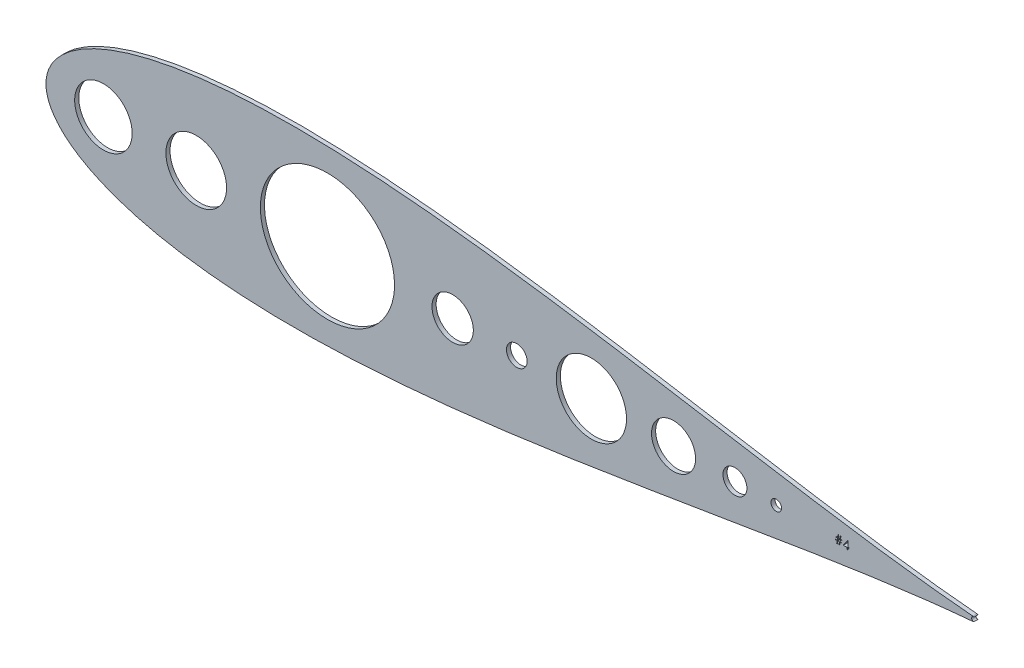
from build123d import *

# Parameters (mm, degrees)
SKETCH2_R           = 17.657288519
SKETCH2_R_2         = 3.25497866
SKETCH2_R_3         = 7.363621317
SKETCH2_R_4         = 13.535095818
SKETCH2_R_5         = 21.574235763
SKETCH2_R_6         = 6.35
SKETCH2_R_7         = 12.7
SKETCH2_R_8         = 18.6309
SKETCH2_RX          = 41.194524799
SKETCH2_RY          = 38.943193852
BOSS_EXTRUDE1_DEPTH = 2.54


with BuildPart() as part:
    # Sketch2 → Boss-Extrude1 (new body)
    with BuildSketch(Plane.XY):
        with BuildLine():
            ThreePointArc((862.057835852, 526.923410091), (860.658736729, 525.688436739), (862.057835852, 524.453463386))
            ThreePointArc((862.057835852, 524.453463386), (861.788236827, 524.341051971), (861.501232881, 524.286750085))
            add(Edge.make_bspline(
                [(861.501232881, 527.090123392), (861.04276604, 527.12824932), (857.587663802, 527.419278859), (850.783262685, 528.048196289), (840.683134449, 529.098875488), (829.484860236, 530.388160821), (817.230535763, 531.923781269), (803.977332742, 533.707300368), (789.782564285, 535.734719529), (774.707698866, 537.995566264), (758.816751695, 540.473757329), (742.176296542, 543.147165675), (724.855101729, 545.988178666), (706.923930227, 548.964043091), (688.455310369, 552.037197326), (669.523414321, 555.165943913), (650.203936089, 558.304950145), (630.574027704, 561.405991177), (610.712257411, 564.418599985), (590.698606531, 567.290963188), (570.614460095, 569.970578433), (550.5426266, 572.405190197), (530.567351759, 574.543540838), (510.774331378, 576.336275734), (491.250703169, 577.736663246), (472.085045057, 578.701468568), (453.367355912, 579.191767184), (435.189024931, 579.173564475), (417.642862385, 578.617984442), (400.823101065, 577.503274422), (384.82567011, 575.813270026), (369.748346926, 573.540353328), (355.691671144, 570.683727016), (342.75962723, 567.252949898), (331.06154295, 563.268128921), (320.714118096, 558.764769511), (311.843009548, 553.802506172), (304.580747656, 548.482037868), (299.049620623, 542.977138704), (295.304959214, 537.578870758), (293.216831654, 532.708559781), (292.373606275, 528.801660543), (292.181554098, 525.688436742), (292.373606275, 522.575212941), (293.216831654, 518.668313703), (295.304959214, 513.798002725), (299.049620623, 508.39973478), (304.580747656, 502.894835616), (311.843009548, 497.574367312), (320.714118096, 492.612103972), (331.06154295, 488.108744562), (342.75962723, 484.123923586), (355.691671144, 480.693146467), (369.748346926, 477.836520155), (384.82567011, 475.563603458), (400.823101065, 473.873599062), (417.642862385, 472.758889041), (435.189024931, 472.203309009), (453.367355912, 472.1851063), (472.085045057, 472.675404915), (491.250703169, 473.640210238), (510.774331378, 475.040597749), (530.567351759, 476.833332645), (550.5426266, 478.971683286), (570.614460095, 481.406295051), (590.698606531, 484.085910295), (610.712257411, 486.958273498), (630.574027704, 489.970882307), (650.203936089, 493.071923339), (669.523414321, 496.210929571), (688.455310369, 499.339676157), (706.923930227, 502.412830392), (724.855101729, 505.388694817), (742.176296542, 508.229707808), (758.816751695, 510.903116155), (774.707698866, 513.38130722), (789.782564285, 515.642153954), (803.977332742, 517.669573115), (817.230535763, 519.453092214), (829.484860236, 520.988712662), (840.683134449, 522.277997995), (850.783262685, 523.328677195), (857.587663802, 523.957594625), (861.04276604, 524.248624163), (861.501232881, 524.286750085)],
                knots=[0.020157042, 0.020157042, 0.020157042, 0.020157042, 0.021270888, 0.028552555, 0.036780684, 0.045920102, 0.055931764, 0.066772884, 0.07839713, 0.090754827, 0.103793165, 0.117456432, 0.131686226, 0.146421738, 0.161599998, 0.177156133, 0.193023668, 0.209134786, 0.225420633, 0.241811602, 0.258237647, 0.274628557, 0.290914287, 0.307025229, 0.322892517, 0.338448342, 0.353626207, 0.368361232, 0.382590428, 0.396252961, 0.409290412, 0.42164701, 0.433269881, 0.444109249, 0.45411864, 0.463255055, 0.471479114, 0.478755289, 0.485052318, 0.490344026, 0.494609833, 0.497833231, 0.5, 0.502166769, 0.505390167, 0.509655974, 0.514947682, 0.521244711, 0.528520886, 0.536744945, 0.54588136, 0.555890751, 0.566730119, 0.57835299, 0.590709588, 0.603747039, 0.617409572, 0.631638768, 0.646373793, 0.661551658, 0.677107483, 0.692974771, 0.709085713, 0.725371443, 0.741762353, 0.758188398, 0.774579367, 0.790865214, 0.806976332, 0.822843867, 0.838400002, 0.853578262, 0.868313774, 0.882543568, 0.896206835, 0.909245173, 0.92160287, 0.933227116, 0.944068236, 0.954079898, 0.963219316, 0.971447445, 0.978729112, 0.979842958, 0.979842958, 0.979842958, 0.979842958], degree=3))
            ThreePointArc((861.501232881, 527.090123392), (861.788236827, 527.035821507), (862.057835852, 526.923410091))
        make_face()
        with Locations((327.506499469, 525.688436739)):
            Circle(SKETCH2_R, mode=Mode.SUBTRACT)
        with Locations((740.701723359, 525.688436739)):
            Circle(SKETCH2_R_2, mode=Mode.SUBTRACT)
        with Locations((715.326071331, 525.688436739)):
            Circle(SKETCH2_R_3, mode=Mode.SUBTRACT)
        with Locations((677.63472234, 525.688436739)):
            Circle(SKETCH2_R_4, mode=Mode.SUBTRACT)
        with Locations((627.159732714, 525.688436739)):
            Circle(SKETCH2_R_5, mode=Mode.SUBTRACT)
        with Locations((581.354660413, 525.688436739)):
            Circle(SKETCH2_R_6, mode=Mode.SUBTRACT)
        with Locations((541.984660413, 525.688436739)):
            Circle(SKETCH2_R_7, mode=Mode.SUBTRACT)
        with Locations((384.504660413, 525.688436739)):
            Circle(SKETCH2_R_8, mode=Mode.SUBTRACT)
        with Locations((465.077935131, 525.688436739)):
            Ellipse(SKETCH2_RX, SKETCH2_RY, mode=Mode.SUBTRACT)
        Polygon((780.86793468, 525.941392586), (780.86793468, 525.61575156), (779.897117368, 525.61575156), (779.633551667, 523.857290023), (779.239729554, 523.857290023), (779.503295255, 525.61575156), (778.464296855, 525.61575156), (778.200731154, 523.857290023), (777.806909041, 523.857290023), (778.070474742, 525.61575156), (777.220755192, 525.61575156), (777.220755192, 525.941392586), (778.119320903, 525.941392586), (778.295370579, 527.113700284), (777.351011604, 527.113700284), (777.351011604, 527.439341309), (778.34421673, 527.439341309), (778.588447504, 529.067546435), (778.981251991, 529.067546435), (778.737021217, 527.439341309), (779.777037242, 527.439341309), (780.021268016, 529.067546435), (780.414072504, 529.067546435), (780.16984173, 527.439341309), (780.998191092, 527.439341309), (780.998191092, 527.113700284), (780.120995579, 527.113700284), (779.945963529, 525.941392586), align=None, mode=Mode.SUBTRACT)
        Polygon((784.617894617, 529.067546435), (784.71049878, 529.067546435), (784.71049878, 525.550623359), (785.296652629, 525.550623359), (785.296652629, 525.029597721), (784.71049878, 525.029597721), (784.71049878, 523.857290023), (784.254601343, 523.857290023), (784.254601343, 525.029597721), (781.844857755, 525.029597721), align=None, mode=Mode.SUBTRACT)
    extrude(amount=BOSS_EXTRUDE1_DEPTH)


solid = part.part
